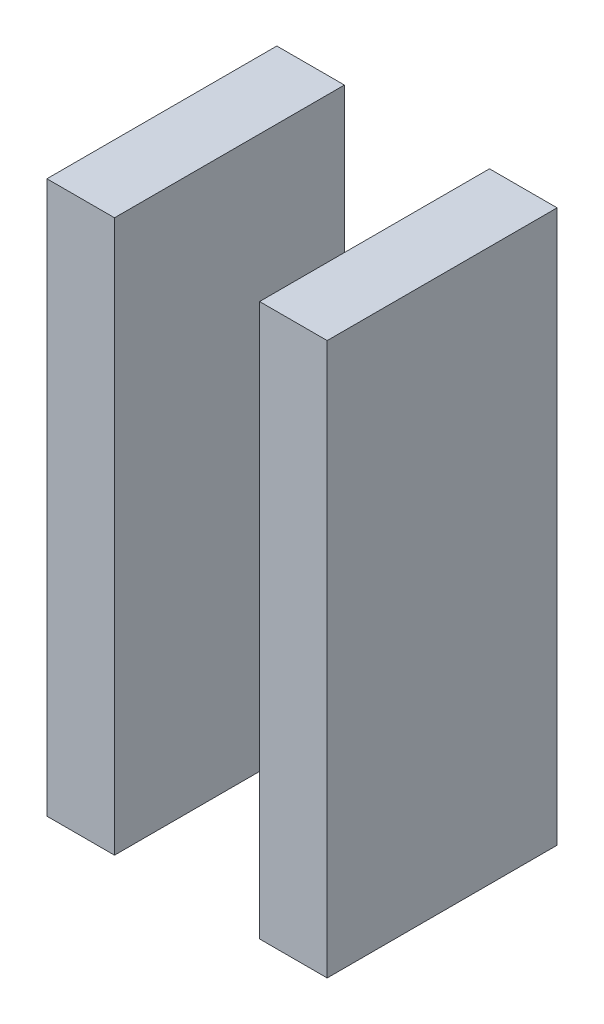
from build123d import *

# Parameters (mm, degrees)
AUFSATZ_LINEAR_START              = 1
SKIZZE1_W                         = 2.94
SKIZZE1_H                         = 24.01
AUFSATZ_LINEAR_AUSTRAGEN1_DEPTH   = 10
AUFSATZ_LINEAR_AUSTRAGEN1_2_DEPTH = 10


with BuildPart() as part:
    # Skizze1 → Aufsatz-Linear austragen1 (new body)
    with BuildSketch(Plane.XY.offset(AUFSATZ_LINEAR_START)):
        with Locations((193.5, -46.1)):
            Rectangle(SKIZZE1_W, SKIZZE1_H)
    extrude(amount=AUFSATZ_LINEAR_AUSTRAGEN1_DEPTH)


with BuildPart() as body_2:
    # Skizze1 → Aufsatz-Linear austragen1 2 (new body)
    with BuildSketch(Plane.XY.offset(AUFSATZ_LINEAR_START)):
        with Locations((202.75, -46.1)):
            Rectangle(SKIZZE1_W, SKIZZE1_H)
    extrude(amount=AUFSATZ_LINEAR_AUSTRAGEN1_2_DEPTH)


solid = Compound([part.part, body_2.part])
